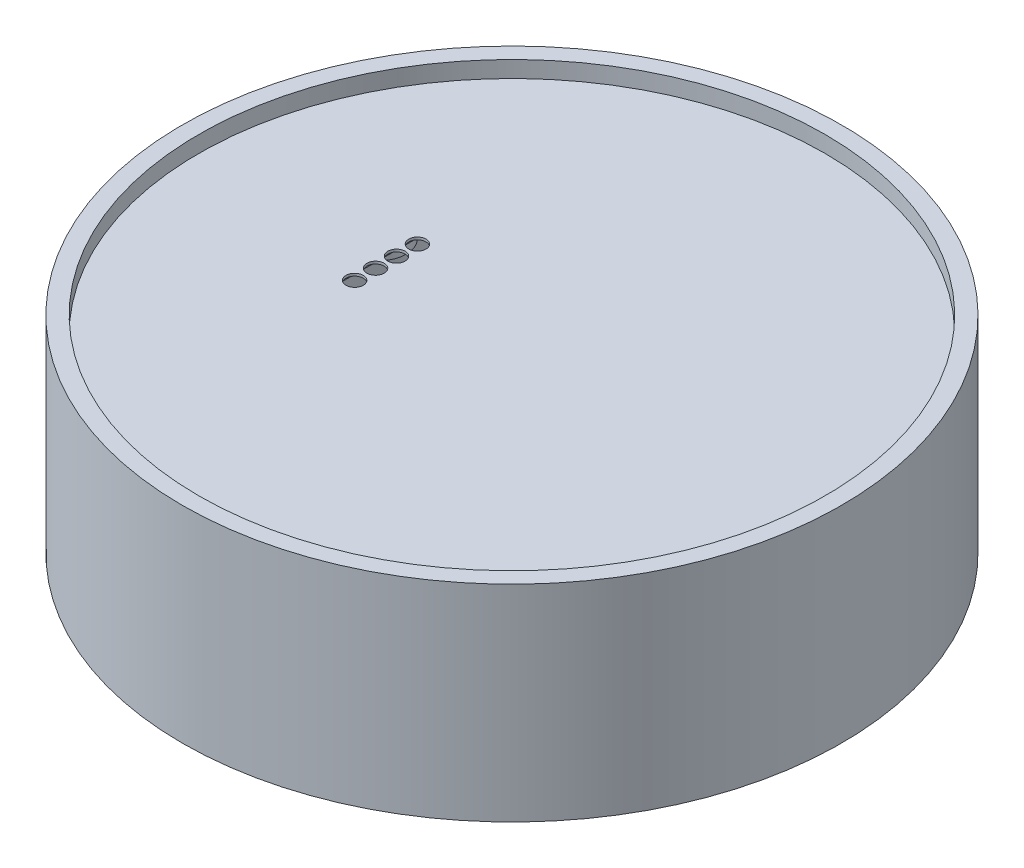
from build123d import *

# Parameters (mm, degrees)
SKETCH1_R           = 40
BOSS_EXTRUDE1_DEPTH = 25
SKETCH2_R           = 38
CUT_EXTRUDE1_DEPTH  = 2
SKETCH3_R           = 37
CUT_EXTRUDE2_DEPTH  = 21.5
SKETCH4_W           = 12.5
SKETCH4_H           = 11.5
CUT_EXTRUDE3_DEPTH  = 41
SKETCH5_R           = 1.05
CUT_EXTRUDE4_DEPTH  = 24
SKETCH6_W           = 4.251934594
SKETCH6_H           = 15.745280186
CUT_EXTRUDE5_DEPTH  = 1.2
SKETCH7_R           = 3.3
SKETCH7_R_2         = 1.5
BOSS_EXTRUDE2_DEPTH = 2.8
FILLET1_R           = 1
SKETCH9_R           = 4.75
SKETCH9_R_2         = 3.25
BOSS_EXTRUDE3_DEPTH = 6.4
SKETCH10_R          = 8
SKETCH10_R_2        = 3
BOSS_EXTRUDE4_DEPTH = 15.5
FILLET3_R           = 4


with BuildPart() as part:
    # Sketch1 → Boss-Extrude1 (new body)
    with BuildSketch(Plane(origin=(0, 0, 0), x_dir=(1, 0, 0), z_dir=(0, 1, 0))):
        with Locations(Location((0, 0, 0), (0, 0, 270))):  # turned: the seam where the file's is
            Circle(SKETCH1_R)
    extrude(amount=-BOSS_EXTRUDE1_DEPTH)

    # Sketch2 → Cut-Extrude1 (cut)
    with BuildSketch(Plane(origin=(0, 0, 0), x_dir=(1, 0, 0), z_dir=(0, 1, 0))):
        with Locations(Location((0, 0, 0), (0, 0, 270))):  # turned: the seam where the file's is
            Circle(SKETCH2_R)
    extrude(amount=-CUT_EXTRUDE1_DEPTH, mode=Mode.SUBTRACT)

    # Sketch3 → Cut-Extrude2 (cut)
    with BuildSketch(Plane.XZ.offset(25)):
        with Locations(Location((0, 0, 0), (0, 0, 270))):  # turned: the seam where the file's is
            Circle(SKETCH3_R)
    extrude(amount=-CUT_EXTRUDE2_DEPTH, mode=Mode.SUBTRACT)

    # Sketch4 → Cut-Extrude3 (cut, through all)
    with BuildSketch(Plane(origin=(0, 0, 0), x_dir=(0, 0, -1), z_dir=(1, 0, 0))):
        with Locations((0, -13.95)):
            Rectangle(SKETCH4_W, SKETCH4_H)
    extrude(amount=-CUT_EXTRUDE3_DEPTH, mode=Mode.SUBTRACT)

    # Sketch5 → Cut-Extrude4 (cut, through all)
    with BuildSketch(Plane(origin=(0, -2, 0), x_dir=(1, 0, 0), z_dir=(0, 1, 0))):
        with Locations(Location((-15.203530433, 3.732709011, 0), (0, 0, 270))):  # turned: the seam where the file's is
            Circle(SKETCH5_R)
        with Locations(Location((-15.203530433, 1.192709011, 0), (0, 0, 270))):  # turned: the seam where the file's is
            Circle(SKETCH5_R)
        with Locations(Location((-15.203530433, -1.347290989, 0), (0, 0, 270))):  # turned: the seam where the file's is
            Circle(SKETCH5_R)
        with Locations(Location((-15.203530433, -3.887290989, 0), (0, 0, 270))):  # turned: the seam where the file's is
            Circle(SKETCH5_R)
    extrude(amount=-CUT_EXTRUDE4_DEPTH, mode=Mode.SUBTRACT)

    # Sketch6 → Cut-Extrude5 (cut)
    with BuildSketch(Plane.XZ.offset(3.5)):
        with Locations((-15.203530433, 0.077290989)):
            Rectangle(SKETCH6_W, SKETCH6_H)
    extrude(amount=-CUT_EXTRUDE5_DEPTH, mode=Mode.SUBTRACT)

    # Sketch7 → Boss-Extrude2 (add)
    with BuildSketch(Plane.XZ.offset(3.5)):
        with Locations(Location((-22.143981065, 6.938197018, 0), (0, 0, 90))):  # turned: the seam where the file's is
            Circle(SKETCH7_R)
        with Locations(Location((-22.143981065, 6.938197018, 0), (0, 0, 270))):  # turned: the seam where the file's is
            Circle(SKETCH7_R_2, mode=Mode.SUBTRACT)
        with Locations(Location((-22.41620863, -6.284446249, 0), (0, 0, 90))):  # turned: the seam where the file's is
            Circle(SKETCH7_R)
        with Locations(Location((-22.41620863, -6.284446249, 0), (0, 0, 270))):  # turned: the seam where the file's is
            Circle(SKETCH7_R_2, mode=Mode.SUBTRACT)
    extrude(amount=BOSS_EXTRUDE2_DEPTH)

    # Fillet1
    fillet1_edges = [part.edges().sort_by_distance(p)[0] for p in [
        (-22.143981065, -3.5, 3.638197018),
    ]]
    fillet(fillet1_edges, radius=FILLET1_R)

    # Sketch9 → Boss-Extrude3 (add)
    with BuildSketch(Plane.XZ.offset(3.5)):
        with Locations(Location((0, 25, 0), (0, 0, 90))):  # turned: the seam where the file's is
            Circle(SKETCH9_R)
        with Locations(Location((0, 25, 0), (0, 0, 270))):  # turned: the seam where the file's is
            Circle(SKETCH9_R_2, mode=Mode.SUBTRACT)
        with Locations(Location((0, -25, 0), (0, 0, 90))):  # turned: the seam where the file's is
            Circle(SKETCH9_R)
        with Locations(Location((0, -25, 0), (0, 0, 90))):  # turned: the seam where the file's is
            Circle(SKETCH9_R_2, mode=Mode.SUBTRACT)
    extrude(amount=BOSS_EXTRUDE3_DEPTH)

    # Sketch10 → Boss-Extrude4 (add)
    with BuildSketch(Plane.XZ.offset(3.5)):
        with Locations(Location((0, 0, 0), (0, 0, 90))):  # turned: the seam where the file's is
            Circle(SKETCH10_R)
        with Locations(Location((0, 0, 0), (0, 0, 90))):  # turned: the seam where the file's is
            Circle(SKETCH10_R_2, mode=Mode.SUBTRACT)
    extrude(amount=BOSS_EXTRUDE4_DEPTH)

    # Fillet3
    fillet3_edges = [part.edges().sort_by_distance(p)[0] for p in [
        (0, -3.5, -8),
    ]]
    fillet(fillet3_edges, radius=FILLET3_R)


solid = part.part
